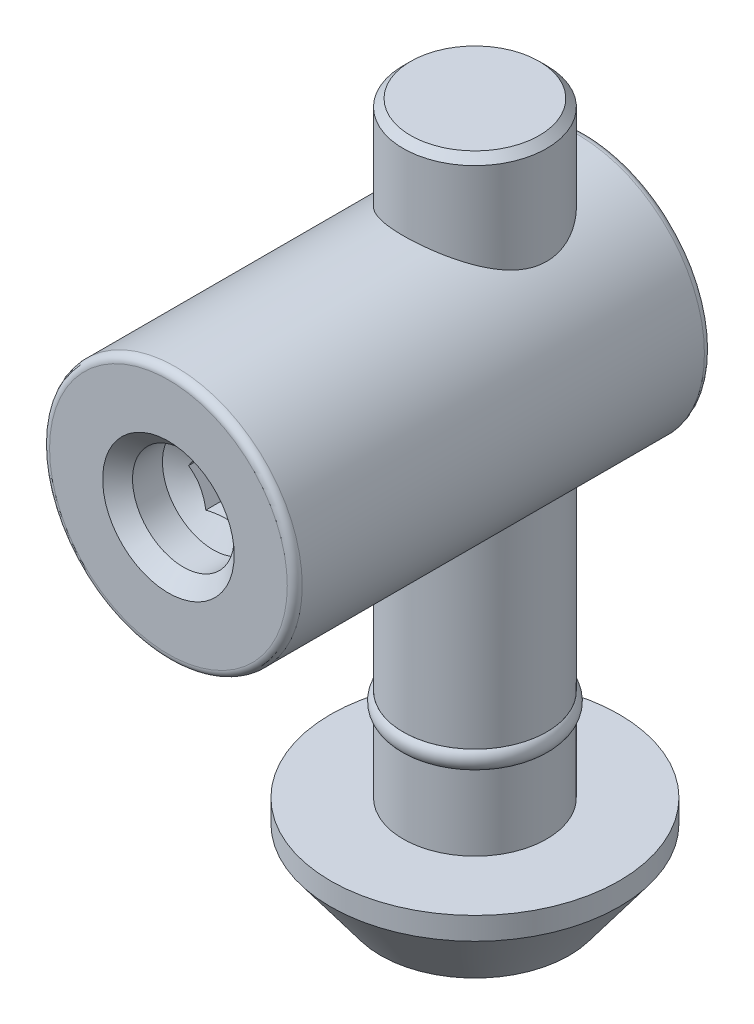
from build123d import *

# Parameters (mm, degrees)
CHAMFER_1_SIZE              = 0.5
SKETCH_12_R                 = 8.45
EXTRUDE_2_DEPTH             = 20.5
EXTRUDE_2_DEPTH_BACK        = 7.4
HOLE_WIZARD_M81_D           = 6.8
HOLE_WIZARD_M81_DEPTH       = 3
HOLE_WIZARD_M81_CSINK_D     = 8.8
HOLE_WIZARD_M81_CSINK_ANGLE = 90
HOLE_WIZARD_M81_TIP         = 2.042926105
FILLET_1_R                  = 0.5
CUT_EXTRUDE_2_DEPTH         = 6


with BuildPart() as part:
    # Эскиз3 → Повернуть1 (revolve)
    with BuildSketch(Plane.XY, mode=Mode.PRIVATE) as revolve_1_sk:
        Polygon((0, 0), (-4.8, 0), (-4.8, -34.3), (-4.3, -34.3), (-4.3, -35.5), (-4.8, -35.5), (-4.8, -40.5), (-9.65, -40.5), (-9.65, -42), (-6.3, -46.5), (0, -46.5), align=None)
    revolve(revolve_1_sk.sketch.rotate(Axis((0, 0, 0), (0, 1, 0)), 270), axis=Axis((0, 0, 0), (0, 1, 0)))  # turned: the seam where the file's is

    # Фаска1
    chamfer_1_edges = [part.edges().sort_by_distance(p)[0] for p in [
        (0, 0, 4.8),
    ]]
    chamfer(chamfer_1_edges, length=CHAMFER_1_SIZE)

    # Эскиз12 → Бобышка-Вытянуть2 (add, two sides)
    with BuildSketch(Plane.XY) as extrude_2_sk:
        with Locations((0, -14)):
            Circle(SKETCH_12_R)
    extrude(amount=EXTRUDE_2_DEPTH)
    extrude(extrude_2_sk.sketch, amount=-EXTRUDE_2_DEPTH_BACK)

    # Отверстие обработанное метчиком M81
    with Locations(Plane.XY.offset(20.5)):
        with Locations((0, -14)):
            CounterSinkHole(HOLE_WIZARD_M81_D / 2, HOLE_WIZARD_M81_CSINK_D / 2, depth=HOLE_WIZARD_M81_DEPTH, counter_sink_angle=HOLE_WIZARD_M81_CSINK_ANGLE)
            with Locations((0, 0, -(HOLE_WIZARD_M81_DEPTH + HOLE_WIZARD_M81_TIP / 2))):  # 118° drill point
                Cone(0, HOLE_WIZARD_M81_D / 2, HOLE_WIZARD_M81_TIP, mode=Mode.SUBTRACT)

    # Скругление1
    fillet_1_edges = [part.edges().sort_by_distance(p)[0] for p in [
        (-8.45, -14, -7.4),
        (-8.45, -14, 20.5),
    ]]
    fillet(fillet_1_edges, radius=FILLET_1_R)

    # Эскиз15 → Вырез-Вытянуть2 (cut)
    with BuildSketch(Plane.XY.offset(20.5)):
        Polygon((2.309401077, -14), (1.154700538, -12), (-1.154700538, -12), (-2.309401077, -14), (-1.154700538, -16), (1.154700538, -16), align=None)
    extrude(amount=-CUT_EXTRUDE_2_DEPTH, mode=Mode.SUBTRACT)


with BuildPart() as body_2:
    # Эскиз16 → Повернуть2 (revolve)
    with BuildSketch(Plane.XY, mode=Mode.PRIVATE) as revolve_2_sk:
        with BuildLine():
            Line((-4.3, -34.3), (-4.8, -34.3))
            ThreePointArc((-4.8, -34.3), (-5.081024968, -34.9), (-4.8, -35.5))
            Line((-4.8, -35.5), (-4.3, -35.5))
            Line((-4.3, -35.5), (-4.3, -34.3))
        make_face()
    revolve(revolve_2_sk.sketch.rotate(Axis((0, -34.3, 0), (0, -1, 0)), 90), axis=Axis((0, -34.3, 0), (0, -1, 0)))  # turned: the seam where the file's is


solid = Compound([part.part, body_2.part])
